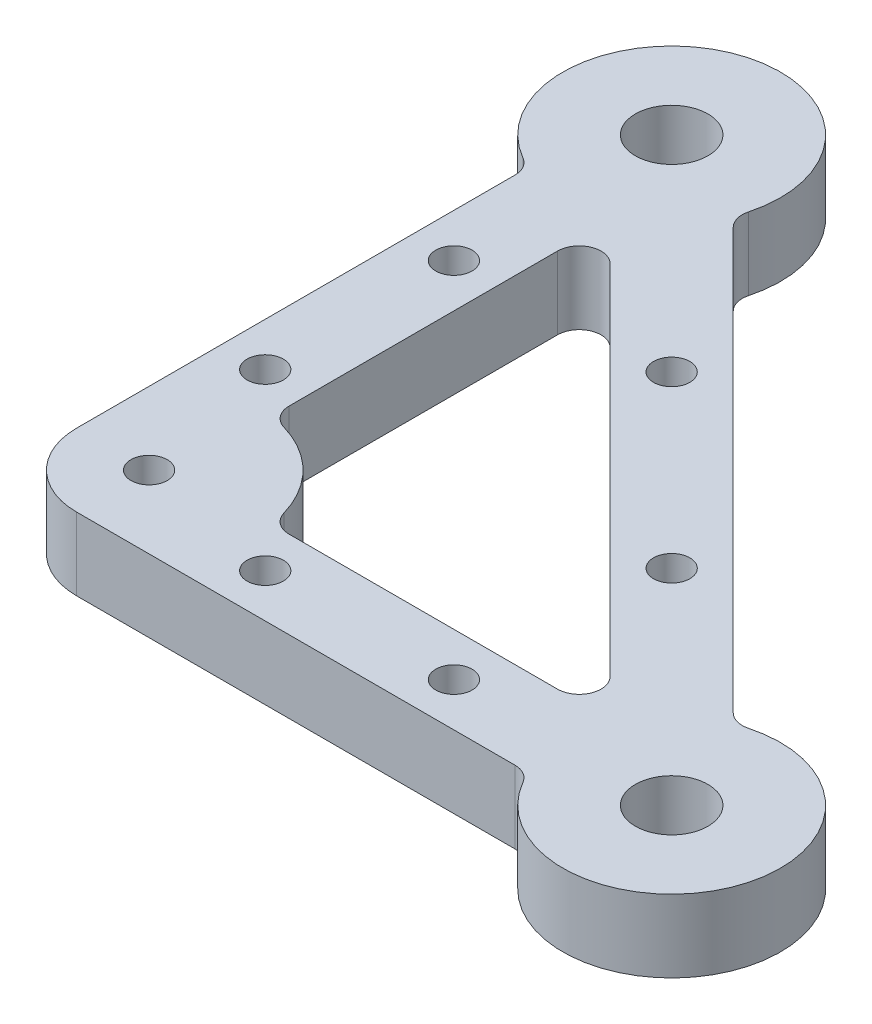
from build123d import *

# Parameters (mm, degrees)
SKETCH1_R           = 5
SKETCH1_R_2         = 2.5
BOSS_EXTRUDE1_DEPTH = 10


with BuildPart() as part:
    # Sketch1 → Boss-Extrude1 (new body)
    with BuildSketch(Plane(origin=(0, 0, 0), x_dir=(1, 0, 0), z_dir=(0, 1, 0))):
        with BuildLine():
            Line((64.411542732, -6), (4, -6))
            ThreePointArc((4, -6), (-3.071067812, -3.071067812), (-6, 4))
            Line((-6, 4), (-6, 64.411542732))
            ThreePointArc((-6, 64.411542732), (-6.401923789, 65.911542732), (-7.5, 67.009618943))
            ThreePointArc((-7.5, 67.009618943), (-5.740251485, 93.858192988), (14.488887394, 76.117714323))
            ThreePointArc((14.488887394, 76.117714323), (14.488887394, 74.564800053), (15.26534453, 73.219936845))
            Line((15.26534453, 73.219936845), (73.219936845, 15.26534453))
            ThreePointArc((73.219936845, 15.26534453), (74.564800053, 14.488887394), (76.117714323, 14.488887394))
            ThreePointArc((76.117714323, 14.488887394), (93.858192988, -5.740251485), (67.009618943, -7.5))
            ThreePointArc((67.009618943, -7.5), (65.911542732, -6.401923789), (64.411542732, -6))
        make_face()
        with Locations((0, 80)):
            Circle(SKETCH1_R, mode=Mode.SUBTRACT)
        with Locations((80, 0)):
            Circle(SKETCH1_R, mode=Mode.SUBTRACT)
        with Locations((28.284271247, 51.715728753)):
            Circle(SKETCH1_R_2, mode=Mode.SUBTRACT)
        with Locations((51.715728753, 28.284271247)):
            Circle(SKETCH1_R_2, mode=Mode.SUBTRACT)
        with Locations((4, 4)):
            Circle(SKETCH1_R_2, mode=Mode.SUBTRACT)
        with Locations((24, 0)):
            Circle(SKETCH1_R_2, mode=Mode.SUBTRACT)
        with Locations((50, 0)):
            Circle(SKETCH1_R_2, mode=Mode.SUBTRACT)
        with Locations((0, 24)):
            Circle(SKETCH1_R_2, mode=Mode.SUBTRACT)
        with Locations((0, 50)):
            Circle(SKETCH1_R_2, mode=Mode.SUBTRACT)
        with BuildLine():
            Line((21.291616466, 6), (58.272077939, 6))
            ThreePointArc((58.272077939, 6), (61.043716536, 7.851949703), (60.393398282, 11.121320344))
            Line((60.393398282, 11.121320344), (11.121320344, 60.393398282))
            ThreePointArc((11.121320344, 60.393398282), (7.851949703, 61.043716536), (6, 58.272077939))
            Line((6, 58.272077939), (6, 21.291616466))
            ThreePointArc((6, 21.291616466), (6.602084238, 19.488840828), (8.166666667, 18.409680388))
            ThreePointArc((8.166666667, 18.409680388), (14.606601718, 14.606601718), (18.409680388, 8.166666667))
            ThreePointArc((18.409680388, 8.166666667), (19.488840828, 6.602084238), (21.291616466, 6))
        make_face(mode=Mode.SUBTRACT)
    extrude(amount=BOSS_EXTRUDE1_DEPTH)


solid = part.part
